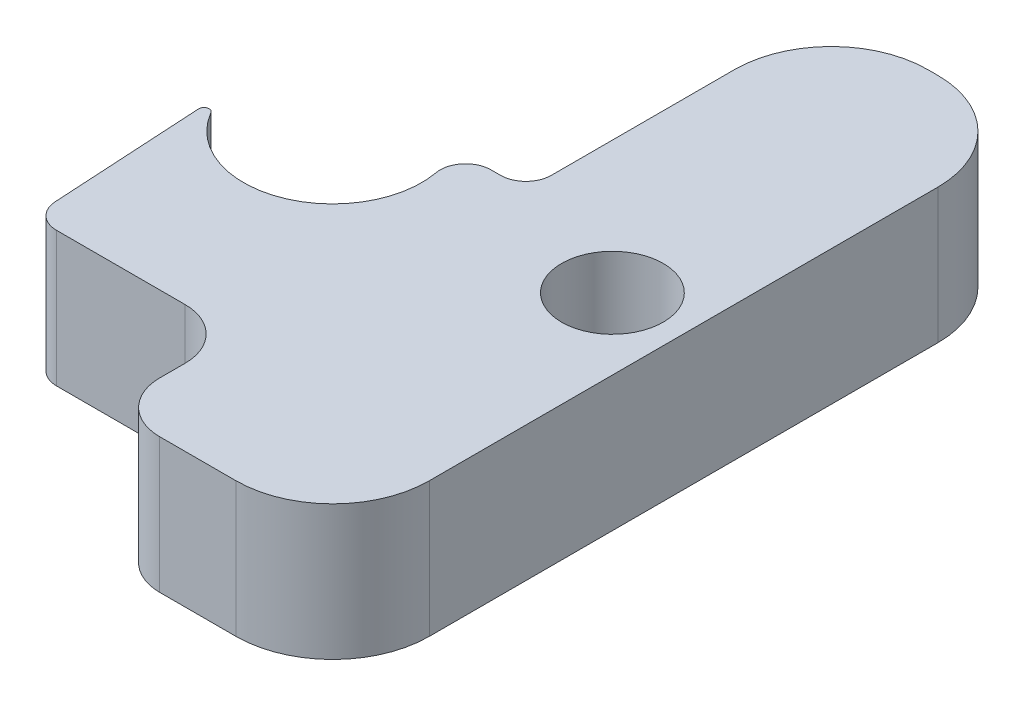
from build123d import *

# Parameters (mm, degrees)
SKETCH1_R           = 1
BOSS_EXTRUDE1_DEPTH = 2.65


with BuildPart() as part:
    # Sketch1 → Boss-Extrude1 (new body)
    with BuildSketch(Plane(origin=(0, 0, 0), x_dir=(1, 0, 0), z_dir=(0, 1, 0))):
        with BuildLine():
            ThreePointArc((4.8, 6.9), (3.456497116, 6.343502884), (2.9, 5))
            Line((2.9, 5), (2.9, 1.4))
            ThreePointArc((2.9, 1.4), (2.753553391, 1.046446609), (2.4, 0.9))
            Line((2.4, 0.9), (2.214158983, 0.9))
            ThreePointArc((2.214158983, 0.9), (1.830463501, 0.720589734), (1.722123653, 0.311111111))
            ThreePointArc((1.722123653, 0.311111111), (0.604527333, -1.642268767), (-1.512826812, -0.879690308))
            ThreePointArc((-1.512826812, -0.879690308), (-1.628066031, -0.834192871), (-1.6991093, -0.935696311))
            Line((-1.6991093, -0.935696311), (-1.527088335, -3.928689929))
            ThreePointArc((-1.527088335, -3.928689929), (-1.371172257, -4.263555336), (-1.027912125, -4.4))
            Line((-1.027912125, -4.4), (1.5, -4.4))
            ThreePointArc((1.5, -4.4), (2.207106781, -4.692893219), (2.5, -5.4))
            Line((2.5, -5.4), (2.5, -5.9))
            ThreePointArc((2.5, -5.9), (2.792893219, -6.607106781), (3.5, -6.9))
            Line((3.5, -6.9), (5, -6.9))
            ThreePointArc((5, -6.9), (6.343502884, -6.343502884), (6.9, -5))
            Line((6.9, -5), (6.9, 5))
            ThreePointArc((6.9, 5), (6.343502884, 6.343502884), (5, 6.9))
            Line((5, 6.9), (4.8, 6.9))
        make_face()
        with Locations((5.5, 0)):
            Circle(SKETCH1_R, mode=Mode.SUBTRACT)
    extrude(amount=BOSS_EXTRUDE1_DEPTH)


solid = part.part
